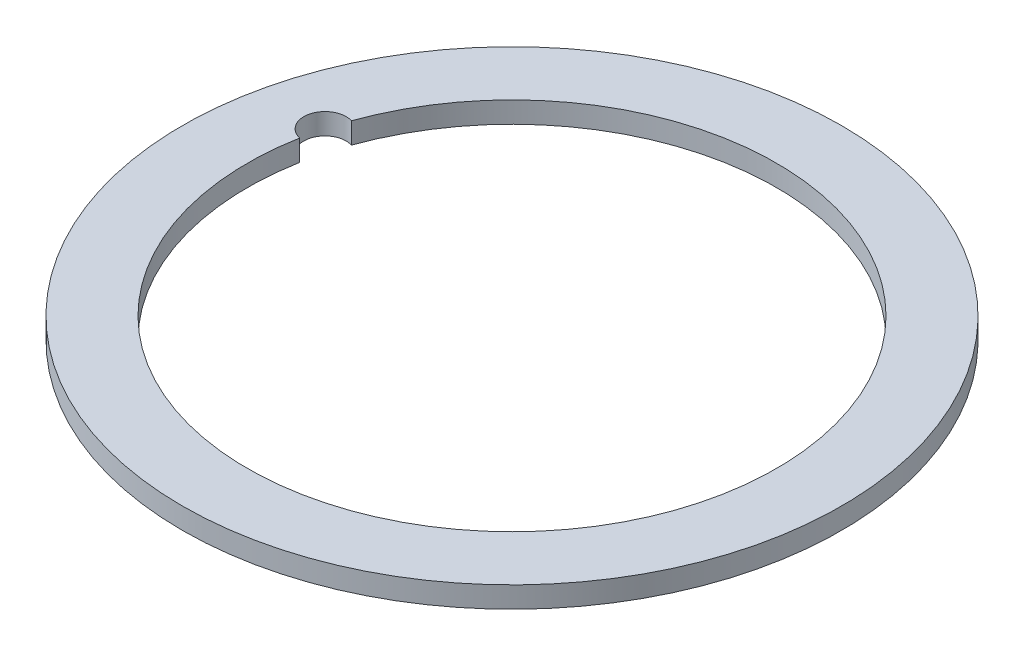
from build123d import *

# Parameters (mm, degrees)
SKETCH2_R           = 49.53
SKETCH2_R_2         = 39.751
BOSS_EXTRUDE1_DEPTH = 3.175
SKETCH3_R           = 3.175
CUT_EXTRUDE1_DEPTH  = 4.175


with BuildPart() as part:
    # Sketch2 → Boss-Extrude1 (new body)
    with BuildSketch(Plane(origin=(0, 0, 0), x_dir=(1, 0, 0), z_dir=(0, 1, 0))):
        Circle(SKETCH2_R)
        Circle(SKETCH2_R_2, mode=Mode.SUBTRACT)
    extrude(amount=BOSS_EXTRUDE1_DEPTH)

    # Sketch3 → Cut-Extrude1 (cut, through all)
    with BuildSketch(Plane(origin=(0, 0, 0), x_dir=(1, 0, 0), z_dir=(0, 1, 0))):
        with Locations((-38.396517521, 10.288315862)):
            Circle(SKETCH3_R)
    extrude(amount=CUT_EXTRUDE1_DEPTH, mode=Mode.SUBTRACT)


solid = part.part
